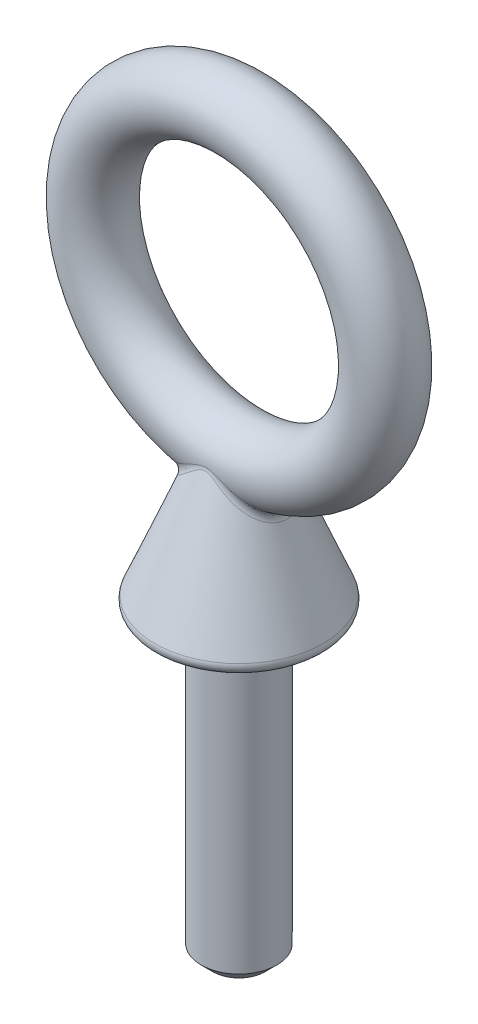
from build123d import *
from build123d.topology import SkipClean

# Parameters (mm, degrees)
BOSS_EXTRUDE1_START = -23.8125
SKETCH2_R           = 3.175
BOSS_EXTRUDE1_DEPTH = 25.4
SKETCH5_OUTSIDE_W   = 67.326
SKETCH5_OUTSIDE_H   = 67.326
SKETCH5_OUTSIDE_R   = 2.21262927
CUT_EXTRUDE1_DEPTH  = 26.793821935
CUT_EXTRUDE1_DRAFT  = -45
SKETCH6_R           = 2.778125
FILLET1_R           = 0.69453125


with BuildPart() as part:
    # Sketch2 → Boss-Extrude1 (new body)
    with BuildSketch(Plane(origin=(0, 0, 0), x_dir=(1, 0, 0), z_dir=(0, 1, 0)).offset(BOSS_EXTRUDE1_START)):
        with Locations(Location((0, 0, 0), (0, 0, 270))):
            Circle(SKETCH2_R)
    extrude(amount=-BOSS_EXTRUDE1_DEPTH)


with BuildPart() as cut_extrude1_tool:
    # Sketch5 outside → Cut-Extrude1 (with draft: the straight prism first)
    with BuildSketch(Plane.XZ.offset(49.2125)):
        Rectangle(SKETCH5_OUTSIDE_W, SKETCH5_OUTSIDE_H)
        Circle(SKETCH5_OUTSIDE_R, mode=Mode.SUBTRACT)
    extrude(amount=-CUT_EXTRUDE1_DEPTH)
    # Cut-Extrude1: the draft: its side faces are tilted about the plane it starts from
    cut_extrude1_sides = [cut_extrude1_tool.faces().sort_by_distance(p)[0] for p in [
        (0, -35.815589033, -33.663),
        (33.663, -35.815589033, 0),
        (0, -35.815589033, 33.663),
        (-33.663, -35.815589033, 0),
        (-2.21262927, -35.815589033, 0),
    ]]
    draft(cut_extrude1_sides, Plane.XZ.offset(49.2125), CUT_EXTRUDE1_DRAFT)


with BuildPart() as part_1:
    add(part.part)

    # Cut-Extrude1: cut by cut_extrude1_tool
    add(cut_extrude1_tool.part, mode=Mode.SUBTRACT)



with BuildPart() as body_2:
    # Sketch6 → Revolve1 (revolve)
    with BuildSketch(Plane(origin=(0, 0, 0), x_dir=(0, 0, -1), z_dir=(1, 0, 0)), mode=Mode.PRIVATE) as revolve1_sk:
        with Locations((0, 12.303125)):
            Circle(SKETCH6_R)
    revolve(revolve1_sk.sketch.rotate(Axis((0, 0, -7.63984375), (0, 0, 1)), 90), axis=Axis((0, 0, -7.63984375), (0, 0, 1)))


with BuildPart() as part_2:
    with SkipClean():  # the faces are left unmerged after this step: merging them gives an invalid solid
        add(part_1.part)

        add(body_2.part)  # Revolve2 merges body 2
        # Sketch8 → Revolve2 (revolve)
        with BuildSketch(Plane.XY, mode=Mode.PRIVATE) as revolve2_sk:
            with BuildLine():
                Line((0, -23.8125), (0, -12.303125))
                Line((0, -12.303125), (-2.778125, -12.303125))
                Line((-2.778125, -12.303125), (-7.092098939, -22.855140441))
                ThreePointArc((-7.092098939, -22.855140441), (-7.025810517, -23.505158098), (-6.44921875, -23.8125))
                Line((-6.44921875, -23.8125), (0, -23.8125))
            make_face()
        revolve(revolve2_sk.sketch.rotate(Axis((0, -23.8125, 0), (0, 1, 0)), 270), axis=Axis((0, -23.8125, 0), (0, 1, 0)))

    # Fillet1
    fillet1_edges = [part_2.edges().sort_by_distance(p)[0] for p in [
        (3.723072169, -14.614473483, -6e-09),
    ]]
    fillet(fillet1_edges, radius=FILLET1_R)


solid = part_2.part
